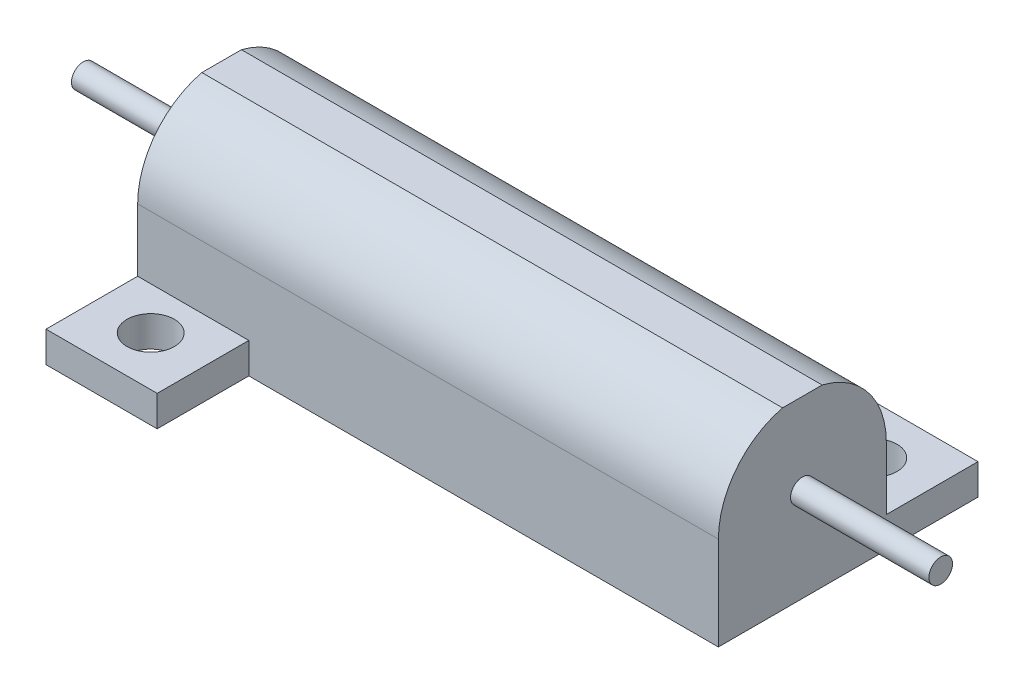
from build123d import *

# Parameters (mm, degrees)
DODANIE_WYCI_GNI_CIE1_DEPTH      = 2.6
SZKIC4_R                         = 2
WYTNIJ_WYCI_GNI_CIE1_DEPTH       = 2.6
SZKIC5_W                         = 49.1
SZKIC5_H                         = 14.2
DODANIE_WYCI_GNI_CIE3_DEPTH      = 5.3
DODANIE_WYCI_GNI_CIE4_DEPTH      = 49.1
SZKIC10_R                        = 1
DODANIE_WYCI_GNI_CIE5_DEPTH      = 11.7
DODANIE_WYCI_GNI_CIE5_DEPTH_BACK = 60.8


with BuildPart() as part:
    # Szkic1 → Dodanie-wyciągnięcie1 (new body)
    with BuildSketch(Plane(origin=(0, 0, 0), x_dir=(1, 0, 0), z_dir=(0, 1, 0))):
        Polygon((0, 0), (0, 21.95), (39.7, 21.95), (39.7, 29.7), (49.1, 29.7), (49.1, 7.75), (9.4, 7.75), (9.4, 0), align=None)
    extrude(amount=DODANIE_WYCI_GNI_CIE1_DEPTH)

    # Szkic4 → Wytnij-wyciągnięcie1 (cut)
    with BuildSketch(Plane.XZ):
        with Locations((4.7, -4.15)):
            Circle(SZKIC4_R)
        with Locations((44.4, -25.55)):
            Circle(SZKIC4_R)
    extrude(amount=-WYTNIJ_WYCI_GNI_CIE1_DEPTH, mode=Mode.SUBTRACT)

    # Szkic5 → Dodanie-wyciągnięcie3 (add)
    with BuildSketch(Plane(origin=(0, 2.6, 0), x_dir=(1, 0, 0), z_dir=(0, 1, 0))):
        with Locations((24.55, 14.85)):
            Rectangle(SZKIC5_W, SZKIC5_H)
    extrude(amount=DODANIE_WYCI_GNI_CIE3_DEPTH)

    # Szkic7 → Dodanie-wyciągnięcie4 (add)
    with BuildSketch(Plane(origin=(0, 0, 0), x_dir=(0, 0, -1), z_dir=(1, 0, 0))):
        with BuildLine():
            Line((13.176679947, 14.8), (16.523320053, 14.8))
            ThreePointArc((16.523320053, 14.8), (14.85, 0.8), (13.176679947, 14.8))
        make_face()
    extrude(amount=DODANIE_WYCI_GNI_CIE4_DEPTH)

    # Szkic10 → Dodanie-wyciągnięcie5 (add, two sides)
    with BuildSketch(Plane.ZY) as dodanie_wyci_gni_cie5_sk:
        with Locations((-14.85, 7.9)):
            Circle(SZKIC10_R)
    extrude(amount=DODANIE_WYCI_GNI_CIE5_DEPTH)
    extrude(dodanie_wyci_gni_cie5_sk.sketch, amount=-DODANIE_WYCI_GNI_CIE5_DEPTH_BACK)


solid = part.part
